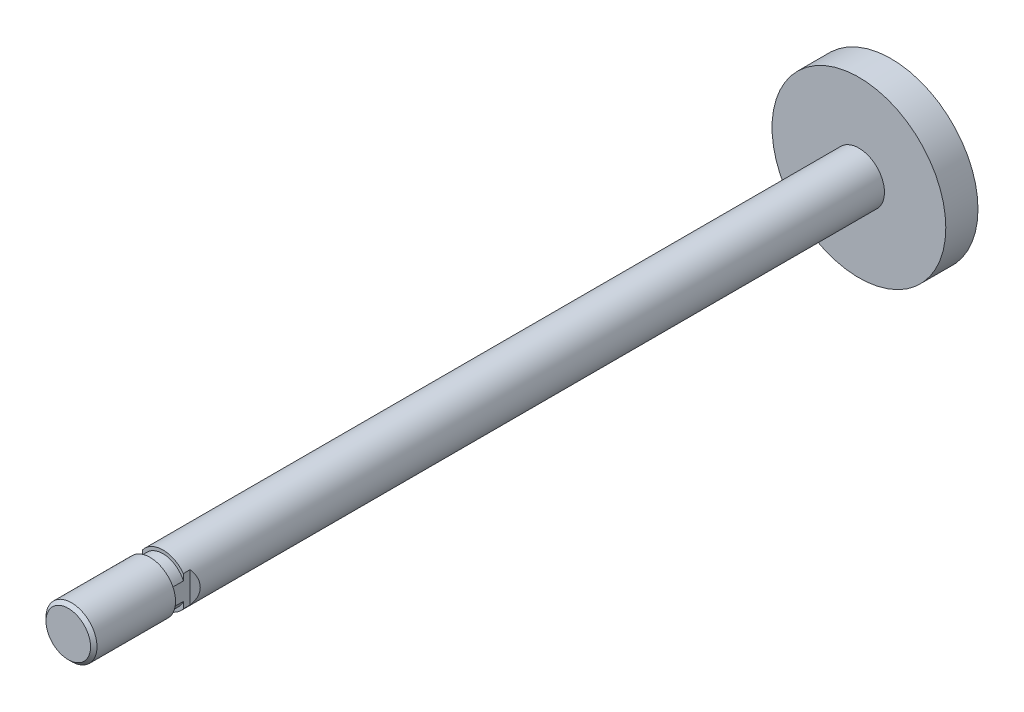
from build123d import *

# Parameters (mm, degrees)
SKETCH1_R        = 3.9624
EXTRUDE1_DEPTH   = 125.2855
SKETCH2_R        = 13.49375
PISTON_DEPTH     = 2.5
FLATS_DEPTH      = 14.49375
FLATS_DEPTH_BACK = 14.49375


with BuildPart() as part:
    # Sketch1 → Extrude1 (new body)
    with BuildSketch(Plane.XY):
        Circle(SKETCH1_R)
    extrude(amount=EXTRUDE1_DEPTH)

    # Sketch2 → Piston (add, symmetric)
    with BuildSketch(Plane.XY):
        Circle(SKETCH2_R)
    extrude(amount=PISTON_DEPTH, both=True)

    # Sketch3 → Threads (revolve, cut)
    with BuildSketch(Plane(origin=(0, 0, 0), x_dir=(0, 0, -1), z_dir=(1, 0, 0))):
        Polygon((-125.2855, 13.49375), (-110.5855, 13.49375), (-110.5855, 3.46), (-112.5855, 3.46), (-112.5855, 3.96), (-124.7855, 3.96), (-125.2855, 3.46), align=None)
    revolve(axis=Axis((0, 0, 0), (0, 0, 1)), mode=Mode.SUBTRACT)

    # Sketch4 → Flats (cut, two sides)
    with BuildSketch(Plane(origin=(0, 0, 0), x_dir=(1, 0, 0), z_dir=(0, 1, 0))) as flats_sk:
        Polygon((3.9624, -112.5855), (3.175, -112.5855), (3.175, -109.5375), (3.9624, -108.7501), align=None)
        Polygon((-3.9624, -108.7501), (-3.9624, -112.5855), (-3.175, -112.5855), (-3.175, -109.5375), align=None)
    extrude(amount=FLATS_DEPTH, mode=Mode.SUBTRACT)
    extrude(flats_sk.sketch, amount=-FLATS_DEPTH_BACK, mode=Mode.SUBTRACT)


solid = part.part
